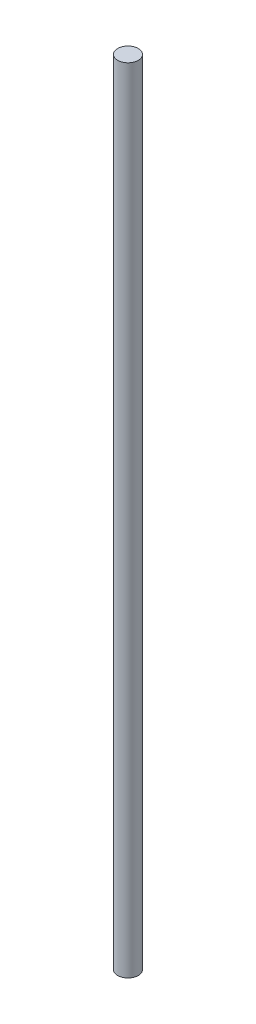
from build123d import *

# Parameters (mm, degrees)
SKETCH1_R           = 5
BOSS_EXTRUDE1_DEPTH = 192.5


with BuildPart() as part:
    # Sketch1 → Boss-Extrude1 (new body, symmetric)
    with BuildSketch(Plane(origin=(0, 0, 0), x_dir=(1, 0, 0), z_dir=(0, 1, 0))):
        Circle(SKETCH1_R)
    extrude(amount=BOSS_EXTRUDE1_DEPTH, both=True)


solid = part.part
